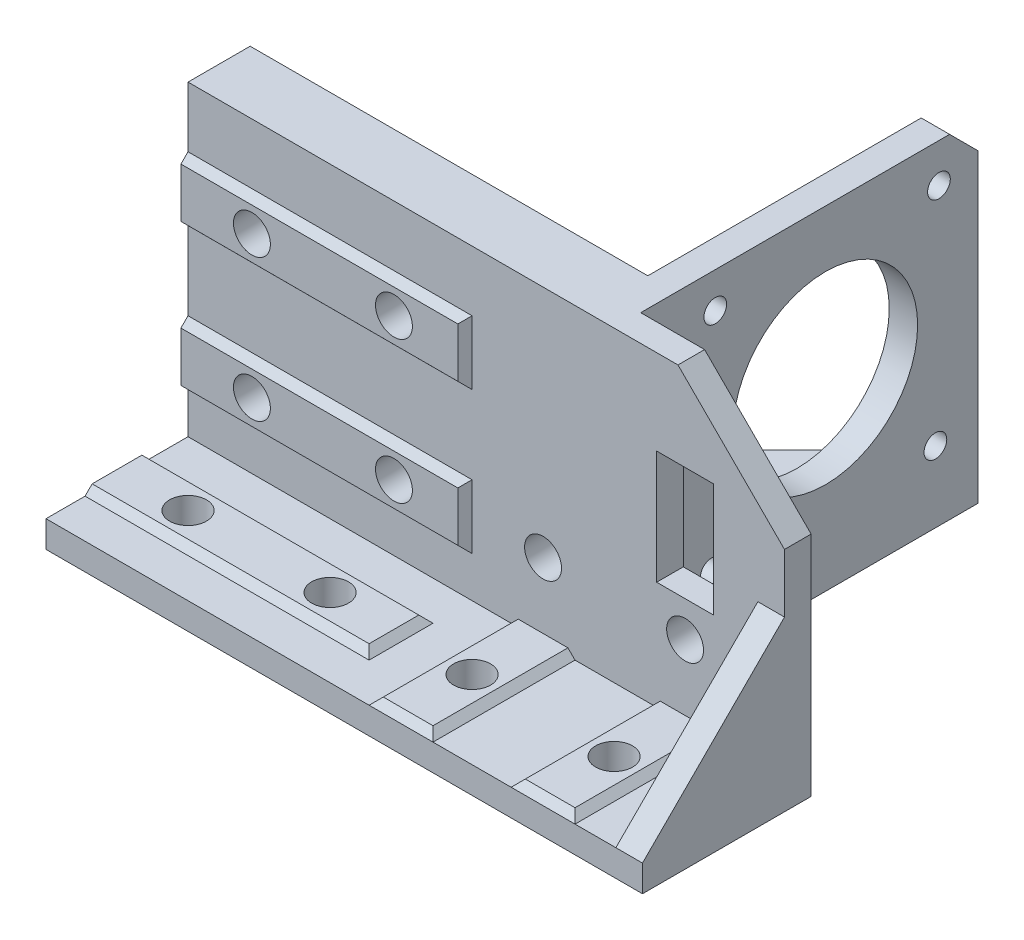
from build123d import *

# Parameters (mm, degrees)
BOSS_EXTRUDE1_DEPTH = 8.75
SKETCH3_W           = 8
SKETCH3_H           = 16
CUT_EXTRUDE1_DEPTH  = 8.75
SKETCH4_W           = 84
SKETCH4_H           = 20
BOSS_EXTRUDE2_DEPTH = 3.75
BOSS_EXTRUDE3_DEPTH = 4.5
BOSS_EXTRUDE5_DEPTH = 4
SKETCH7_R           = 2.6
CUT_EXTRUDE2_DEPTH  = 14
CUT_EXTRUDE3_DEPTH  = 5
SKETCH10_R          = 1.6
SKETCH10_R_2        = 13
CUT_EXTRUDE4_DEPTH  = 5
SKETCH11_R          = 4.5
CUT_EXTRUDE5_DEPTH  = 5
SKETCH12_R          = 2.6
CUT_EXTRUDE6_DEPTH  = 3.75
SKETCH13_W          = 40
SKETCH13_H          = 9
BOSS_EXTRUDE6_DEPTH = 1
CUT_EXTRUDE14_DEPTH = 31
CUT_EXTRUDE15_DEPTH = 42
SKETCH17_W          = 40
SKETCH17_H          = 9
BOSS_EXTRUDE7_DEPTH = 1
CUT_EXTRUDE16_DEPTH = 10
CUT_EXTRUDE17_DEPTH = 40
SKETCH20_W          = 9
SKETCH20_H          = 20
BOSS_EXTRUDE8_DEPTH = 1
CUT_EXTRUDE19_DEPTH = 20
CUT_EXTRUDE20_DEPTH = 30
SKETCH23_R          = 2.6
CUT_EXTRUDE21_DEPTH = 1
SKETCH24_R          = 2.6
CUT_EXTRUDE22_DEPTH = 12
BOSS_EXTRUDE9_DEPTH = 3.75


with BuildPart() as part:
    # Sketch1 → Boss-Extrude1 (new body)
    with BuildSketch(Plane.XY):
        Polygon((0, 0), (0, 47), (69, 47), (84, 32), (84, 0), align=None)
    extrude(amount=BOSS_EXTRUDE1_DEPTH)

    # Sketch3 → Cut-Extrude1 (cut)
    with BuildSketch(Plane.XY.offset(8.75)):
        with Locations((70, 27)):
            Rectangle(SKETCH3_W, SKETCH3_H)
    extrude(amount=-CUT_EXTRUDE1_DEPTH, mode=Mode.SUBTRACT)

    # Sketch4 → Boss-Extrude2 (add)
    with BuildSketch(Plane.XZ):
        with Locations((42, 18.75)):
            Rectangle(SKETCH4_W, SKETCH4_H)
    extrude(amount=-BOSS_EXTRUDE2_DEPTH)

    # Sketch5 → Boss-Extrude3 (add)
    with BuildSketch(Plane.XZ):
        Polygon((60, -42.5), (56, -42.5), (13.5, 0), (60, 0), align=None)
    extrude(amount=-BOSS_EXTRUDE3_DEPTH)

    # Sketch6 → Boss-Extrude5 (add)
    with BuildSketch(Plane(origin=(60, 0, 0), x_dir=(0, 0, -1), z_dir=(1, 0, 0))):
        Polygon((0, 0), (0, 47), (38.5, 47), (42.5, 43), (42.5, 0), align=None)
    extrude(amount=-BOSS_EXTRUDE5_DEPTH)

    # Sketch7 → Cut-Extrude2 (cut)
    with BuildSketch(Plane(origin=(0, 0, 0), x_dir=(-1, 0, 0), z_dir=(0, 0, -1))):
        with Locations((-70, 14)):
            Circle(SKETCH7_R)
    extrude(amount=-CUT_EXTRUDE2_DEPTH, mode=Mode.SUBTRACT)

    # Sketch9 → Cut-Extrude3 (cut)
    with BuildSketch(Plane(origin=(0, 0, 0), x_dir=(-1, 0, 0), z_dir=(0, 0, -1))):
        Polygon((-84, 0), (-84, 32), (-69, 47), (-60, 47), (-60, 0), align=None)
    extrude(amount=-CUT_EXTRUDE3_DEPTH, mode=Mode.SUBTRACT)

    # Sketch10 → Cut-Extrude4 (cut)
    with BuildSketch(Plane(origin=(60, 0, 0), x_dir=(0, 0, -1), z_dir=(1, 0, 0))):
        with Locations((5.5, 42)):
            Circle(SKETCH10_R)
        with Locations((21, 26)):
            Circle(SKETCH10_R_2)
        with Locations((37, 41.5)):
            Circle(SKETCH10_R)
        with Locations((36.5, 10)):
            Circle(SKETCH10_R)
        with Locations((5, 10.5)):
            Circle(SKETCH10_R)
    extrude(amount=-CUT_EXTRUDE4_DEPTH, mode=Mode.SUBTRACT)

    # Sketch11 → Cut-Extrude5 (cut)
    with BuildSketch(Plane(origin=(0, 0, 0), x_dir=(-1, 0, 0), z_dir=(0, 0, -1))):
        with Locations((-50, 14)):
            Circle(SKETCH11_R)
        with Locations((-30, 14)):
            Circle(SKETCH11_R)
        with Locations((-10, 14)):
            Circle(SKETCH11_R)
        with Locations((-10, 34)):
            Circle(SKETCH11_R)
        with Locations((-30, 34)):
            Circle(SKETCH11_R)
    extrude(amount=-CUT_EXTRUDE5_DEPTH, mode=Mode.SUBTRACT)

    # Sketch12 → Cut-Extrude6 (cut)
    with BuildSketch(Plane(origin=(0, 0, 5), x_dir=(-1, 0, 0), z_dir=(0, 0, -1))):
        with Locations((-30, 34)):
            Circle(SKETCH12_R)
        with Locations((-10, 34)):
            Circle(SKETCH12_R)
        with Locations((-10, 14)):
            Circle(SKETCH12_R)
        with Locations((-30, 14)):
            Circle(SKETCH12_R)
        with Locations((-50, 14)):
            Circle(SKETCH12_R)
    extrude(amount=-CUT_EXTRUDE6_DEPTH, mode=Mode.SUBTRACT)

    # Sketch13 → Boss-Extrude6 (add)
    with BuildSketch(Plane.XY.offset(8.75)):
        with Locations((20, 34)):
            Rectangle(SKETCH13_W, SKETCH13_H)
        with Locations((20, 14)):
            Rectangle(SKETCH13_W, SKETCH13_H)
    extrude(amount=BOSS_EXTRUDE6_DEPTH)

    # Sketch16 → Cut-Extrude14 (cut)
    with BuildSketch(Plane(origin=(0, 38.5, 0), x_dir=(1, 0, 0), z_dir=(0, 1, 0))):
        Polygon((40, -8.75), (39, -9.75), (40, -9.75), align=None)
    extrude(amount=-CUT_EXTRUDE14_DEPTH, mode=Mode.SUBTRACT)

    # Sketch14 → Cut-Extrude15 (cut)
    with BuildSketch(Plane.ZY):
        Polygon((8.75, 38.5), (9.75, 37.5), (9.75, 38.5), align=None)
        Polygon((9.75, 29.5), (9.75, 30.502721412), (8.75, 29.5), align=None)
        Polygon((9.75, 18.5), (8.75, 18.5), (9.75, 17.5), align=None)
        Polygon((9.75, 9.5), (9.75, 10.5), (8.75, 9.5), align=None)
    extrude(amount=-CUT_EXTRUDE15_DEPTH, mode=Mode.SUBTRACT)

    # Sketch17 → Boss-Extrude7 (add)
    with BuildSketch(Plane(origin=(0, 3.75, 0), x_dir=(1, 0, 0), z_dir=(0, 1, 0))):
        with Locations((20, -18.75)):
            Rectangle(SKETCH17_W, SKETCH17_H)
    extrude(amount=BOSS_EXTRUDE7_DEPTH)

    # Sketch18 → Cut-Extrude16 (cut)
    with BuildSketch(Plane.XY.offset(23.25)):
        Polygon((40, 4.75), (39, 4.75), (40, 3.75), align=None)
    extrude(amount=-CUT_EXTRUDE16_DEPTH, mode=Mode.SUBTRACT)

    # Sketch19 → Cut-Extrude17 (cut)
    with BuildSketch(Plane.ZY):
        Polygon((14.25, 4.75), (14.25, 3.75), (15.25, 4.75), align=None)
        Polygon((23.25, 4.75), (23.25, 3.75), (22.25, 4.75), align=None)
    extrude(amount=-CUT_EXTRUDE17_DEPTH, mode=Mode.SUBTRACT)

    # Sketch20 → Boss-Extrude8 (add)
    with BuildSketch(Plane(origin=(0, 3.75, 0), x_dir=(1, 0, 0), z_dir=(0, 1, 0))):
        with Locations((50, -18.75)):
            Rectangle(SKETCH20_W, SKETCH20_H)
        with Locations((70, -18.75)):
            Rectangle(SKETCH20_W, SKETCH20_H)
    extrude(amount=BOSS_EXTRUDE8_DEPTH)

    # Sketch22 → Cut-Extrude19 (cut)
    with BuildSketch(Plane.XY.offset(28.75)):
        Polygon((45.5, 3.75), (45.5, 4.75), (46.5, 4.75), align=None)
        Polygon((54.5, 4.75), (54.5, 3.75), (53.5, 4.75), align=None)
        Polygon((65.5, 4.75), (66.5, 4.75), (65.5, 3.75), align=None)
        Polygon((74.5, 4.75), (74.5, 3.75), (73.5, 4.75), align=None)
    extrude(amount=-CUT_EXTRUDE19_DEPTH, mode=Mode.SUBTRACT)

    # Sketch21 → Cut-Extrude20 (cut)
    with BuildSketch(Plane.ZY.offset(-45.5)):
        Polygon((28.75, 3.75), (28.75, 4.75), (27.75, 4.75), align=None)
    extrude(amount=-CUT_EXTRUDE20_DEPTH, mode=Mode.SUBTRACT)

    # Sketch23 → Cut-Extrude21 (cut)
    with BuildSketch(Plane(origin=(0, 0, 8.75), x_dir=(-1, 0, 0), z_dir=(0, 0, -1))):
        with Locations((-30, 34)):
            Circle(SKETCH23_R)
        with Locations((-10, 34)):
            Circle(SKETCH23_R)
        with Locations((-30, 14)):
            Circle(SKETCH23_R)
        with Locations((-10, 14)):
            Circle(SKETCH23_R)
    extrude(amount=-CUT_EXTRUDE21_DEPTH, mode=Mode.SUBTRACT)

    # Sketch24 → Cut-Extrude22 (cut)
    with BuildSketch(Plane(origin=(0, 4.75, 0), x_dir=(1, 0, 0), z_dir=(0, 1, 0))):
        with Locations((10, -18.75)):
            Circle(SKETCH24_R)
        with Locations((30, -18.75)):
            Circle(SKETCH24_R)
        with Locations((50, -18.75)):
            Circle(SKETCH24_R)
        with Locations((70, -18.75)):
            Circle(SKETCH24_R)
    extrude(amount=-CUT_EXTRUDE22_DEPTH, mode=Mode.SUBTRACT)

    # Sketch25 → Boss-Extrude9 (add)
    with BuildSketch(Plane(origin=(84, 0, 0), x_dir=(0, 0, -1), z_dir=(1, 0, 0))):
        Polygon((-8.75, 23.75), (-28.75, 3.75), (-8.75, 3.75), align=None)
    extrude(amount=-BOSS_EXTRUDE9_DEPTH)


solid = part.part
